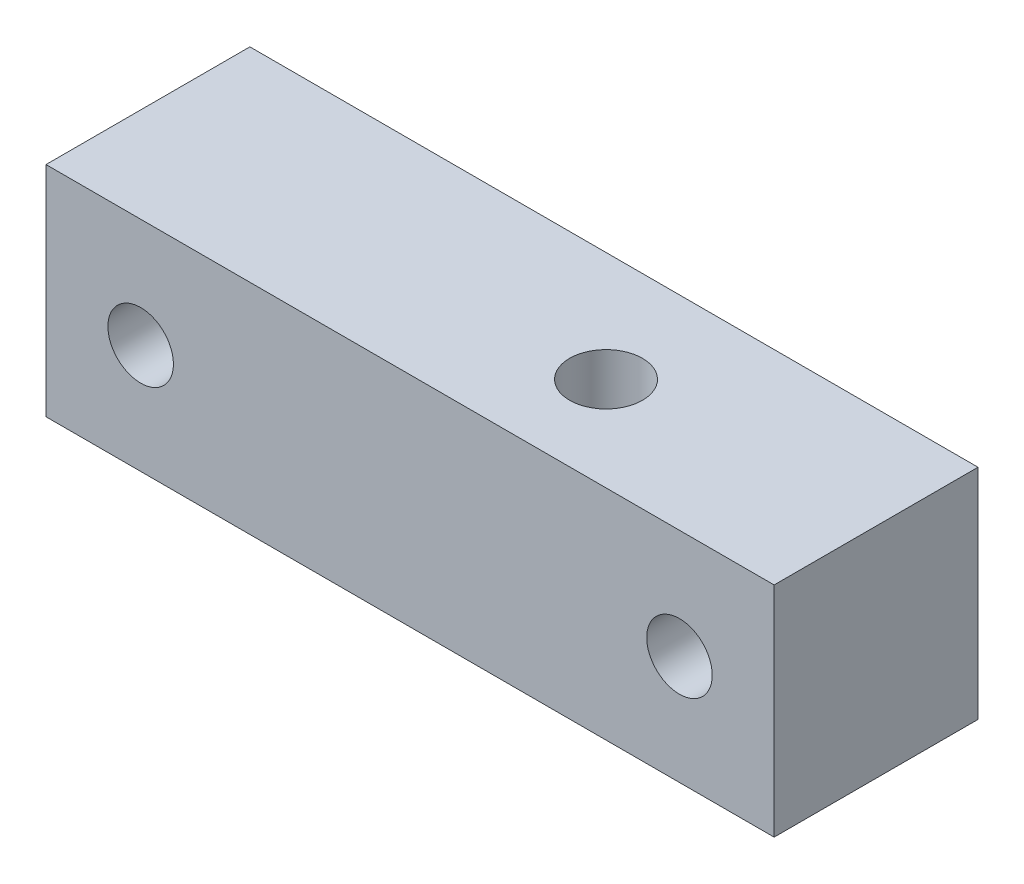
from build123d import *

# Parameters (mm, degrees)
SKETCH1_W           = 50
SKETCH1_H           = 15
BOSS_EXTRUDE1_DEPTH = 14
SKETCH2_R           = 2.5
CUT_EXTRUDE1_DEPTH  = 16
SKETCH3_R           = 2.25
CUT_EXTRUDE2_DEPTH  = 15


with BuildPart() as part:
    # Sketch1 → Boss-Extrude1 (new body)
    with BuildSketch(Plane.XY):
        with Locations((25, 7.5)):
            Rectangle(SKETCH1_W, SKETCH1_H)
    extrude(amount=BOSS_EXTRUDE1_DEPTH)

    # Sketch2 → Cut-Extrude1 (cut, through all)
    with BuildSketch(Plane(origin=(0, 15, 0), x_dir=(1, 0, 0), z_dir=(0, 1, 0))):
        with Locations((32, -7.541991602)):
            Circle(SKETCH2_R)
    extrude(amount=-CUT_EXTRUDE1_DEPTH, mode=Mode.SUBTRACT)

    # Sketch3 → Cut-Extrude2 (cut, through all)
    with BuildSketch(Plane.XY.offset(14)):
        with Locations((6.5, 7.5)):
            Circle(SKETCH3_R)
        with Locations((43.5, 7.5)):
            Circle(SKETCH3_R)
    extrude(amount=-CUT_EXTRUDE2_DEPTH, mode=Mode.SUBTRACT)


solid = part.part
